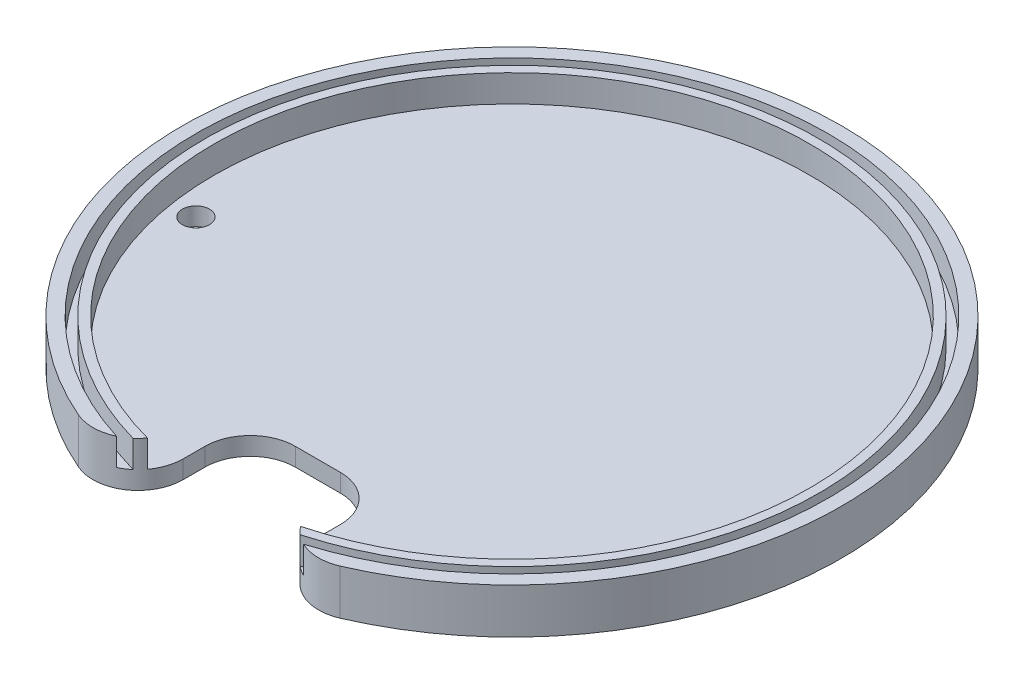
from build123d import *

# Parameters (mm, degrees)
SKETCH1_R           = 73
BOSS_EXTRUDE1_DEPTH = 4
SKETCH2_R           = 73
SKETCH2_R_2         = 70
SKETCH2_R_3         = 68
SKETCH2_R_4         = 66
BOSS_EXTRUDE2_DEPTH = 6
CUT_EXTRUDE1_REACH  = 105.721
SKETCH4_W           = 30
SKETCH4_H           = 30
FILLET1_R           = 10
FILLET2_R           = 10
CUT_EXTRUDE2_REACH  = 105.721
SKETCH6_R           = 3


with BuildPart() as part:
    # Sketch1 → Boss-Extrude1 (new body)
    with BuildSketch(Plane(origin=(0, 0, 0), x_dir=(1, 0, 0), z_dir=(0, 1, 0))):
        with Locations(Location((0, 0, 0), (0, 0, 270))):
            Circle(SKETCH1_R)
    extrude(amount=BOSS_EXTRUDE1_DEPTH)

    # Sketch2 → Boss-Extrude2 (add)
    with BuildSketch(Plane(origin=(0, 4, 0), x_dir=(1, 0, 0), z_dir=(0, 1, 0))):
        with Locations(Location((0, 0, 0), (0, 0, 270))):
            Circle(SKETCH2_R)
        with Locations(Location((0, 0, 0), (0, 0, 270))):
            Circle(SKETCH2_R_2, mode=Mode.SUBTRACT)
        with Locations(Location((0, 0, 0), (0, 0, 270))):
            Circle(SKETCH2_R_3)
        with Locations(Location((0, 0, 0), (0, 0, 270))):
            Circle(SKETCH2_R_4, mode=Mode.SUBTRACT)
    extrude(amount=BOSS_EXTRUDE2_DEPTH)

    # Sketch4 → Cut-Extrude1 (cut, up to next)
    with BuildSketch(Plane.XZ, mode=Mode.PRIVATE) as cut_extrude1_sk1:
        with Locations((0, 58)):
            Rectangle(SKETCH4_W, SKETCH4_H)
    cut_extrude1_tool1 = extrude(cut_extrude1_sk1.sketch, amount=-CUT_EXTRUDE1_REACH, mode=Mode.PRIVATE) & part.part
    add(cut_extrude1_tool1.solids().sort_by_distance((0, 0, 58))[0], mode=Mode.SUBTRACT)

    # Fillet1
    fillet1_edges = [part.edges().sort_by_distance(p)[0] for p in [
        (15, 5, 71.442284398),
        (-15, 5, 71.442284398),
    ]]
    fillet(fillet1_edges, radius=FILLET1_R)

    # Fillet2
    fillet2_edges = [part.edges().sort_by_distance(p)[0] for p in [
        (-15, 2, 43),
        (15, 2, 43),
    ]]
    fillet(fillet2_edges, radius=FILLET2_R)

    # Sketch6 → Cut-Extrude2 (cut, up to next)
    with BuildSketch(Plane.XZ, mode=Mode.PRIVATE) as cut_extrude2_sk1:
        with Locations(Location((-60, 10, 0), (0, 0, 270))):
            Circle(SKETCH6_R)
    cut_extrude2_tool1 = extrude(cut_extrude2_sk1.sketch, amount=-CUT_EXTRUDE2_REACH, mode=Mode.PRIVATE) & part.part
    add(cut_extrude2_tool1.solids().sort_by_distance((-60, 0, 10))[0], mode=Mode.SUBTRACT)


solid = part.part
